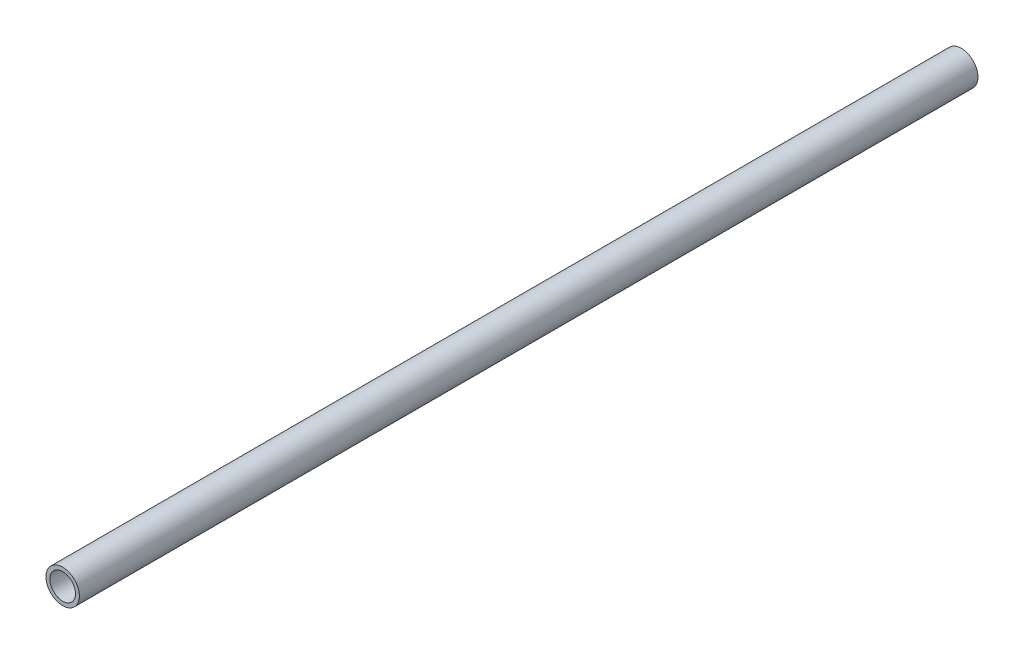
from build123d import *

# Parameters (mm, degrees)
CROQUIS1_R              = 6.5
CROQUIS1_R_2            = 5
SALIENTE_EXTRUIR1_DEPTH = 175


with BuildPart() as part:
    # Croquis1 → Saliente-Extruir1 (new body, symmetric)
    with BuildSketch(Plane.XY):
        Circle(CROQUIS1_R)
        Circle(CROQUIS1_R_2, mode=Mode.SUBTRACT)
    extrude(amount=SALIENTE_EXTRUIR1_DEPTH, both=True)


solid = part.part
